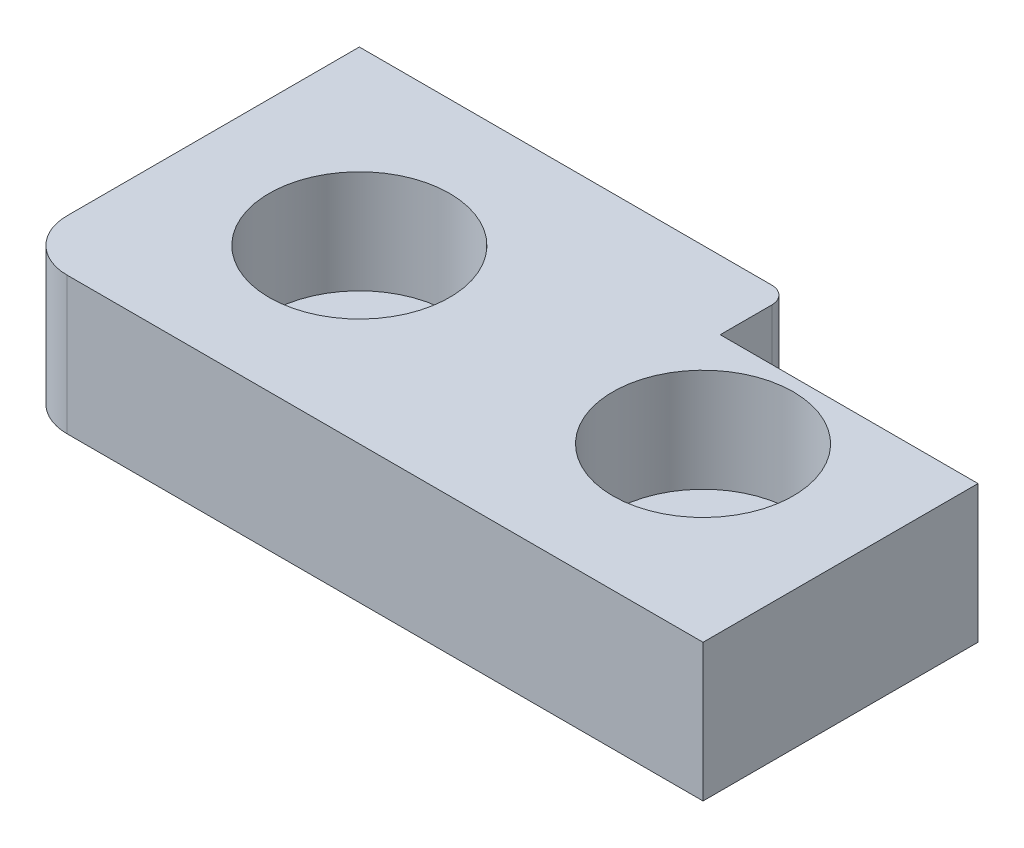
from build123d import *

# Parameters (mm, degrees)
BOSS_EXTRUDE1_DEPTH            = 8
CBORE_FOR_M5_SHCS1_D           = 5.5
CBORE_FOR_M5_SHCS1_DEPTH       = 8
CBORE_FOR_M5_SHCS1_CBORE_D     = 10.5
CBORE_FOR_M5_SHCS1_CBORE_DEPTH = 6


with BuildPart() as part:
    # Sketch1 → Boss-Extrude1 (new body)
    with BuildSketch(Plane(origin=(0, 0, 0), x_dir=(1, 0, 0), z_dir=(0, 1, 0))):
        with BuildLine():
            Line((3, 0), (37, 0))
            Line((37, 0), (40, 0))
            Line((40, 0), (40, 3))
            Line((40, 3), (40, 16))
            Line((40, 16), (25, 16))
            Line((25, 16), (25, 19))
            ThreePointArc((25, 19), (24.707106781, 19.707106781), (24, 20))
            Line((24, 20), (0, 20))
            Line((0, 20), (0, 3))
            ThreePointArc((0, 3), (0.878679656, 0.878679656), (3, 0))
        make_face()
    extrude(amount=BOSS_EXTRUDE1_DEPTH)

    # CBORE for M5 SHCS1
    with Locations(Plane(origin=(0, 8, 0), x_dir=(1, 0, 0), z_dir=(0, 1, 0))):
        with Locations((30, 10), (10, 10)):
            CounterBoreHole(CBORE_FOR_M5_SHCS1_D / 2, CBORE_FOR_M5_SHCS1_CBORE_D / 2, CBORE_FOR_M5_SHCS1_CBORE_DEPTH, depth=CBORE_FOR_M5_SHCS1_DEPTH)


solid = part.part
